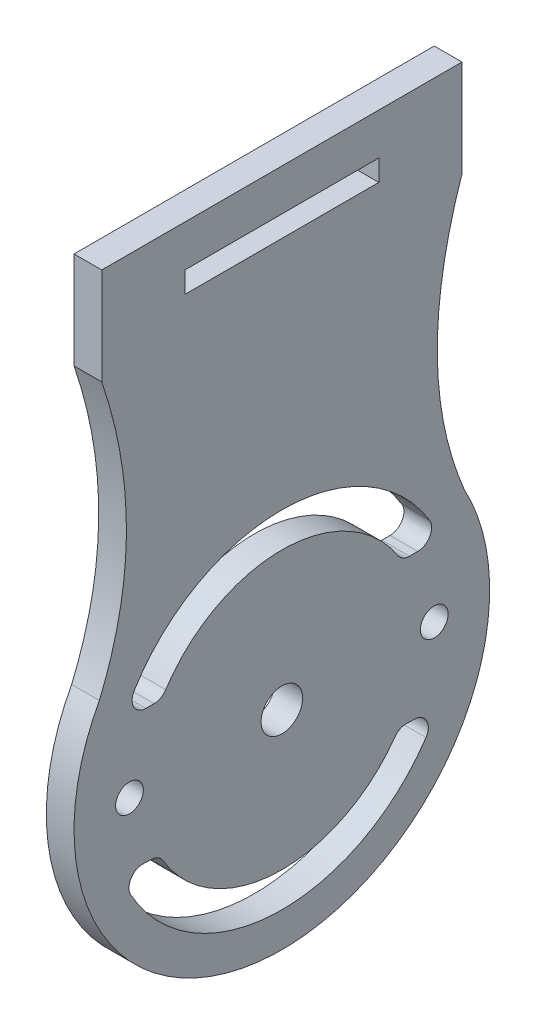
from build123d import *

# Parameters (mm, degrees)
RESSALTO_EXTRUS_O1_DEPTH = 2
ESBO_O2_R                = 1.5
ESBO_O2_R_2              = 1
ESBO_O2_W                = 14
ESBO_O2_H                = 1.527880785
CORTE_EXTRUS_O1_DEPTH    = 3.0000001


with BuildPart() as part:
    # Esboço1 → Ressalto-extrusão1 (new body)
    with BuildSketch(Plane(origin=(0, 0, 0), x_dir=(0, 0, -1), z_dir=(1, 0, 0))):
        with BuildLine():
            Line((-13, 34), (0, 34))
            Line((0, 34), (0, -15))
            ThreePointArc((0, -15), (-12.895532653, -7.661934325), (-13.173963237, 7.172634986))
            add(Edge.make_bspline(
                [(-13, 27), (-9.354199414, 16.239964162), (-13.173963237, 7.172634986)],
                knots=[0, 0, 0, 0.912495845, 0.912495845, 0.912495845], degree=2))
            Line((-13, 27), (-13, 34))
        make_face()
    ressalto_extrus_o1 = extrude(amount=RESSALTO_EXTRUS_O1_DEPTH)

    # Espelhar1: Ressalto-extrusão1 across plane
    add(ressalto_extrus_o1.mirror(Plane(origin=(2, 34, 0), x_dir=(1, 0, 0), z_dir=(0, 0, 1))))

    # Esboço2 → Corte-extrusão1 (cut, through all)
    with BuildSketch(Plane(origin=(2, 0, 0), x_dir=(0, 0, -1), z_dir=(1, 0, 0))):
        Circle(ESBO_O2_R)
        with Locations((11, 0)):
            Circle(ESBO_O2_R_2)
        with Locations((-11, 0)):
            Circle(ESBO_O2_R_2)
        with Locations((0, 30.236059608)):
            Rectangle(ESBO_O2_W, ESBO_O2_H)
        with BuildLine():
            Line((-9.810708435, 5), (-9.219544457, 5))
            ThreePointArc((-9.219544457, 5), (-8.742813163, 5.120950927), (-8.381404052, 5.454545455))
            ThreePointArc((-8.381404052, 5.454545455), (0, 10), (8.381404052, 5.454545455))
            ThreePointArc((8.381404052, 5.454545455), (8.742813163, 5.120950927), (9.219544457, 5))
            Line((9.219544457, 5), (9.810708435, 5))
            ThreePointArc((9.810708435, 5), (10.682986811, 5.510990353), (10.663813516, 6.52173913))
            ThreePointArc((10.663813516, 6.52173913), (0, 12.5), (-10.663813516, 6.52173913))
            ThreePointArc((-10.663813516, 6.52173913), (-10.682986811, 5.510990353), (-9.810708435, 5))
        make_face()
        with BuildLine():
            Line((-9.996736389, -4.616845413), (-9.40601466, -4.639707772))
            ThreePointArc((-9.40601466, -4.639707772), (-8.934317599, -4.779005068), (-8.586080114, -5.126326976))
            ThreePointArc((-8.586080114, -5.126326976), (-0.386734657, -9.992519017), (8.164187762, -5.77460286))
            ThreePointArc((8.164187762, -5.77460286), (8.538227759, -5.455234837), (9.019280003, -5.352811245))
            Line((9.019280003, -5.352811245), (9.610001733, -5.375673604))
            ThreePointArc((9.610001733, -5.375673604), (10.461865791, -5.920015714), (10.403617681, -6.929266854))
            ThreePointArc((10.403617681, -6.929266854), (-0.483418321, -12.490648771), (-10.90805419, -6.104453603))
            ThreePointArc((-10.90805419, -6.104453603), (-10.888123983, -5.093719467), (-9.996736389, -4.616845413))
        make_face()
    extrude(amount=-CORTE_EXTRUS_O1_DEPTH, mode=Mode.SUBTRACT)


solid = part.part
